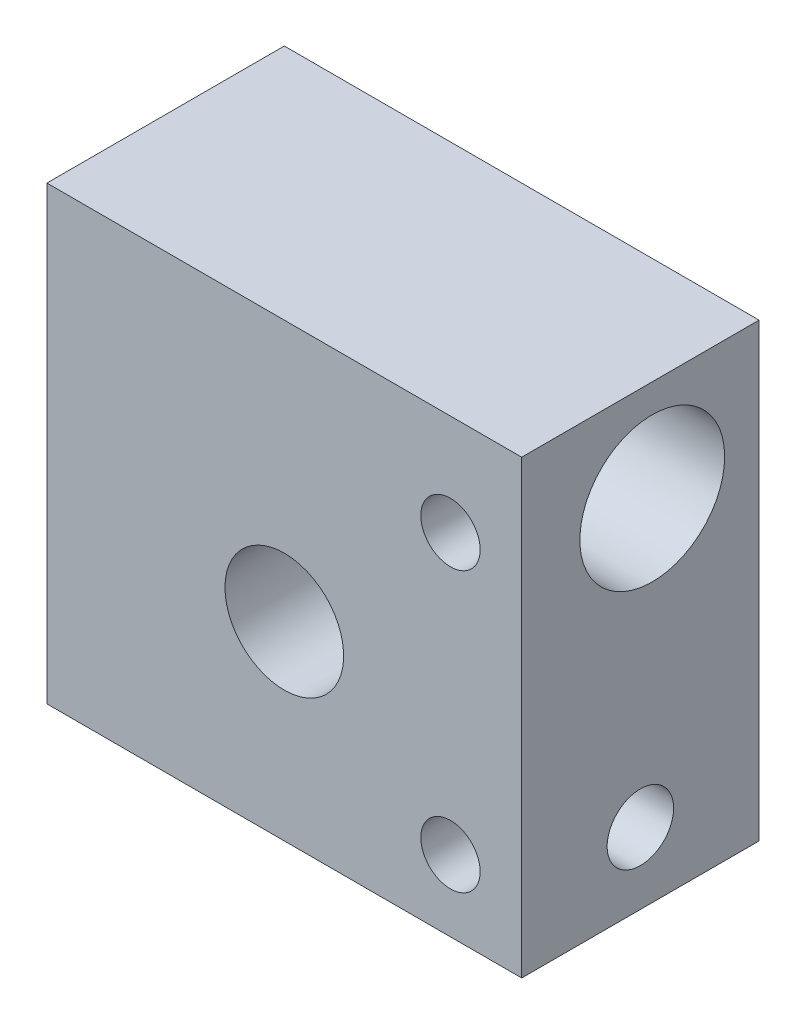
from build123d import *

# Parameters (mm, degrees)
SKETCH1_W                           = 20
SKETCH1_H                           = 19
BOSS_EXTRUDE1_DEPTH                 = 10
SKETCH2_R                           = 2.5
CUT_EXTRUDE1_DEPTH                  = 18.036725037
SKETCH3_R                           = 3.05
CUT_EXTRUDE2_DEPTH                  = 25.295061227
DI_METRO_DE_TALADRO_2_8_2_8_1_D     = 2.8
DI_METRO_DE_TALADRO_2_8_2_8_1_DEPTH = 14
DI_METRO_DE_TALADRO_2_8_2_8_1_TIP   = 0.841204867
TALADRO_ROSCADO_M31_REACH           = 22.387
TALADRO_ROSCADO_M31_BORE_R          = 1.25


with BuildPart() as part:
    # Sketch1 → Boss-Extrude1 (new body)
    with BuildSketch(Plane.XY):
        Rectangle(SKETCH1_W, SKETCH1_H)
    extrude(amount=BOSS_EXTRUDE1_DEPTH)

    # Sketch2 → Cut-Extrude1 (cut, through all)
    with BuildSketch(Plane(origin=(0, 0, 0), x_dir=(-1, 0, 0), z_dir=(0, 0, -1))):
        with Locations((0, -1.5)):
            Circle(SKETCH2_R)
    extrude(amount=-CUT_EXTRUDE1_DEPTH, mode=Mode.SUBTRACT)

    # Sketch3 → Cut-Extrude2 (cut, through all)
    with BuildSketch(Plane(origin=(10, 0, 0), x_dir=(0, 0, -1), z_dir=(1, 0, 0))):
        with Locations((-4.5, 5.25)):
            Circle(SKETCH3_R)
    extrude(amount=-CUT_EXTRUDE2_DEPTH, mode=Mode.SUBTRACT)

    # Diámetro de taladro Ø2.8 (2.8)1
    with Locations(Plane(origin=(10, 0, 0), x_dir=(0, 0, -1), z_dir=(1, 0, 0))):
        with Locations((-5, -6.5)):
            Hole(DI_METRO_DE_TALADRO_2_8_2_8_1_D / 2, depth=DI_METRO_DE_TALADRO_2_8_2_8_1_DEPTH)
            with Locations((0, 0, -(DI_METRO_DE_TALADRO_2_8_2_8_1_DEPTH + DI_METRO_DE_TALADRO_2_8_2_8_1_TIP / 2))):  # 118° drill point
                Cone(0, DI_METRO_DE_TALADRO_2_8_2_8_1_D / 2, DI_METRO_DE_TALADRO_2_8_2_8_1_TIP, mode=Mode.SUBTRACT)

    # Taladro roscado M31 bore → Taladro roscado M31 (cut, up to next)
    with BuildSketch(Plane(origin=(-2.648652683, -2.97524228, 10), x_dir=(1, 0, 0), z_dir=(0, 0, 1)), mode=Mode.PRIVATE) as taladro_roscado_m31_sk1:
        with Locations((9.648652683, 8.22524228)):
            Circle(TALADRO_ROSCADO_M31_BORE_R)
    taladro_roscado_m31_tool1 = extrude(taladro_roscado_m31_sk1.sketch, amount=-TALADRO_ROSCADO_M31_REACH, mode=Mode.PRIVATE) & part.part
    # Taladro roscado M31 bore → Taladro roscado M31 (cut, up to next)
    with BuildSketch(Plane(origin=(-2.648652683, -2.97524228, 10), x_dir=(1, 0, 0), z_dir=(0, 0, 1)), mode=Mode.PRIVATE) as taladro_roscado_m31_sk2:
        with Locations((9.648652683, -3.52475772)):
            Circle(TALADRO_ROSCADO_M31_BORE_R)
    taladro_roscado_m31_tool2 = extrude(taladro_roscado_m31_sk2.sketch, amount=-TALADRO_ROSCADO_M31_REACH, mode=Mode.PRIVATE) & part.part
    add(taladro_roscado_m31_tool1.solids().sort_by_distance((7, 5.25, 10))[0], mode=Mode.SUBTRACT)
    add(taladro_roscado_m31_tool2.solids().sort_by_distance((7, -6.5, 10))[0], mode=Mode.SUBTRACT)


solid = part.part
